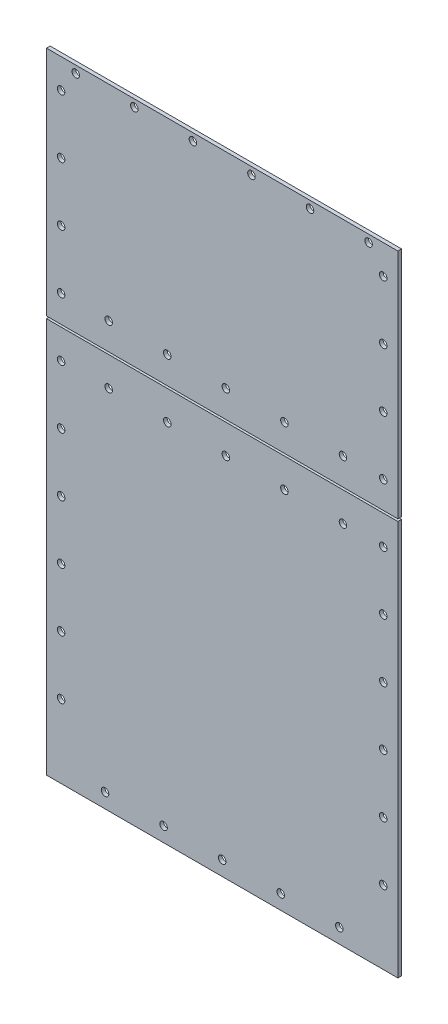
from build123d import *

# Parameters (mm, degrees)
SKETCH1_W             = 152.4
SKETCH1_H             = 100.6
SKETCH1_R             = 1.63195
BOSS_EXTRUDE1_DEPTH   = 1.5875
SKETCH1_H_2           = 171.45
BOSS_EXTRUDE1_2_DEPTH = 1.5875


with BuildPart() as part:
    # Sketch1 → Boss-Extrude1 (new body)
    with BuildSketch(Plane.XY):
        with Locations((76.2, -50.3)):
            Rectangle(SKETCH1_W, SKETCH1_H)
        with Locations((6.35, -88.9)):
            Circle(SKETCH1_R, mode=Mode.SUBTRACT)
        with Locations((26.99, -88.9)):
            Circle(SKETCH1_R, mode=Mode.SUBTRACT)
        with Locations((52.39, -88.9)):
            Circle(SKETCH1_R, mode=Mode.SUBTRACT)
        with Locations((6.35, -63.5)):
            Circle(SKETCH1_R, mode=Mode.SUBTRACT)
        with Locations((6.35, -38.1)):
            Circle(SKETCH1_R, mode=Mode.SUBTRACT)
        with Locations((6.35, -12.7)):
            Circle(SKETCH1_R, mode=Mode.SUBTRACT)
        with Locations((12.7, -3.175)):
            Circle(SKETCH1_R, mode=Mode.SUBTRACT)
        with Locations((38.1, -3.175)):
            Circle(SKETCH1_R, mode=Mode.SUBTRACT)
        with Locations((63.5, -3.175)):
            Circle(SKETCH1_R, mode=Mode.SUBTRACT)
        with Locations((77.79, -88.9)):
            Circle(SKETCH1_R, mode=Mode.SUBTRACT)
        with Locations((103.19, -88.9)):
            Circle(SKETCH1_R, mode=Mode.SUBTRACT)
        with Locations((128.59, -88.9)):
            Circle(SKETCH1_R, mode=Mode.SUBTRACT)
        with Locations((146.05, -88.9)):
            Circle(SKETCH1_R, mode=Mode.SUBTRACT)
        with Locations((88.9, -3.175)):
            Circle(SKETCH1_R, mode=Mode.SUBTRACT)
        with Locations((146.05, -63.5)):
            Circle(SKETCH1_R, mode=Mode.SUBTRACT)
        with Locations((146.05, -38.1)):
            Circle(SKETCH1_R, mode=Mode.SUBTRACT)
        with Locations((114.3, -3.175)):
            Circle(SKETCH1_R, mode=Mode.SUBTRACT)
        with Locations((139.7, -3.175)):
            Circle(SKETCH1_R, mode=Mode.SUBTRACT)
        with Locations((146.05, -12.7)):
            Circle(SKETCH1_R, mode=Mode.SUBTRACT)
    extrude(amount=BOSS_EXTRUDE1_DEPTH)


with BuildPart() as body_2:
    # Sketch1 → Boss-Extrude1 2 (new body)
    with BuildSketch(Plane.XY):
        with Locations((76.2, -187.325)):
            Rectangle(SKETCH1_W, SKETCH1_H_2)
        with Locations((6.35, -241.3)):
            Circle(SKETCH1_R, mode=Mode.SUBTRACT)
        with Locations((25.4, -266.7)):
            Circle(SKETCH1_R, mode=Mode.SUBTRACT)
        with Locations((6.35, -215.9)):
            Circle(SKETCH1_R, mode=Mode.SUBTRACT)
        with Locations((50.8, -266.7)):
            Circle(SKETCH1_R, mode=Mode.SUBTRACT)
        with Locations((76.2, -266.7)):
            Circle(SKETCH1_R, mode=Mode.SUBTRACT)
        with Locations((6.35, -190.5)):
            Circle(SKETCH1_R, mode=Mode.SUBTRACT)
        with Locations((6.35, -165.1)):
            Circle(SKETCH1_R, mode=Mode.SUBTRACT)
        with Locations((6.35, -139.7)):
            Circle(SKETCH1_R, mode=Mode.SUBTRACT)
        with Locations((101.6, -266.7)):
            Circle(SKETCH1_R, mode=Mode.SUBTRACT)
        with Locations((127, -266.7)):
            Circle(SKETCH1_R, mode=Mode.SUBTRACT)
        with Locations((146.05, -241.3)):
            Circle(SKETCH1_R, mode=Mode.SUBTRACT)
        with Locations((146.05, -215.9)):
            Circle(SKETCH1_R, mode=Mode.SUBTRACT)
        with Locations((146.05, -190.5)):
            Circle(SKETCH1_R, mode=Mode.SUBTRACT)
        with Locations((146.05, -165.1)):
            Circle(SKETCH1_R, mode=Mode.SUBTRACT)
        with Locations((146.05, -139.7)):
            Circle(SKETCH1_R, mode=Mode.SUBTRACT)
        with Locations((6.35, -114.3)):
            Circle(SKETCH1_R, mode=Mode.SUBTRACT)
        with Locations((26.99, -114.3)):
            Circle(SKETCH1_R, mode=Mode.SUBTRACT)
        with Locations((52.39, -114.3)):
            Circle(SKETCH1_R, mode=Mode.SUBTRACT)
        with Locations((77.79, -114.3)):
            Circle(SKETCH1_R, mode=Mode.SUBTRACT)
        with Locations((103.19, -114.3)):
            Circle(SKETCH1_R, mode=Mode.SUBTRACT)
        with Locations((128.59, -114.3)):
            Circle(SKETCH1_R, mode=Mode.SUBTRACT)
        with Locations((146.05, -114.3)):
            Circle(SKETCH1_R, mode=Mode.SUBTRACT)
    extrude(amount=BOSS_EXTRUDE1_2_DEPTH)


solid = Compound([part.part, body_2.part])
